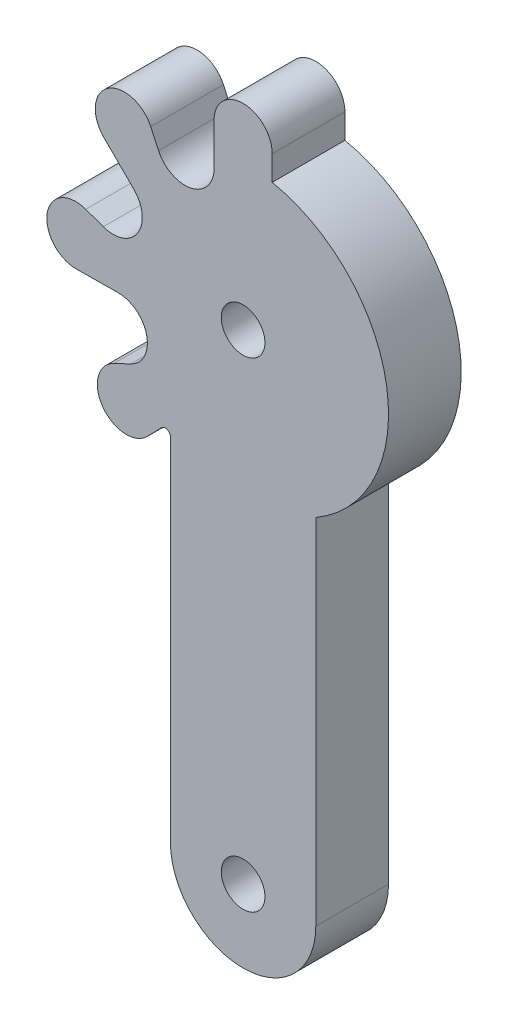
from build123d import *

# Parameters (mm, degrees)
SKETCH2_R           = 1.5
BOSS_EXTRUDE1_DEPTH = 5


with BuildPart() as part:
    # Sketch2 → Boss-Extrude1 (new body)
    with BuildSketch(Plane.XY):
        with BuildLine():
            Line((5, -33), (5, -8.660254038))
            ThreePointArc((5, -8.660254038), (9.870667346, 1.603098918), (2.002269745, 9.797495388))
            Line((2.002269745, 9.797495388), (2.00266405, 11.49953636))
            Line((2.00266405, 11.49953636), (2.002664157, 11.499999691))
            ThreePointArc((2.002664157, 11.499999691), (0.002664157, 13.499999691), (-1.997335843, 11.499999691))
            Line((-1.997335843, 11.499999691), (-1.998003665, 8.617307095))
            ThreePointArc((-1.998003665, 8.617307095), (-3.567262635, 6.664705601), (-5.812270881, 7.776085051))
            Line((-5.812270881, 7.776085051), (-6.351761581, 8.938967191))
            ThreePointArc((-6.351761581, 8.938967191), (-9.315039529, 9.734283484), (-9.574251776, 6.677102885))
            Line((-9.574251776, 6.677102885), (-7.526953052, 4.647039677))
            ThreePointArc((-7.526953052, 4.647039677), (-7.244787999, 2.157941439), (-9.614515081, 1.345771067))
            Line((-9.614515081, 1.345771067), (-10.820227093, 1.781203427))
            ThreePointArc((-10.820227093, 1.781203427), (-13.469614339, 0.244947506), (-11.499566198, -2.099886252))
            Line((-11.499566198, -2.099886252), (-11.463831285, -2.099566981))
            Line((-11.463831285, -2.099566981), (-8.600020221, -2.073980428))
            ThreePointArc((-8.600020221, -2.073980428), (-6.633040893, -3.625608638), (-7.724488765, -5.880669462))
            Line((-7.724488765, -5.880669462), (-7.993660259, -6.008443697))
            Line((-7.993660259, -6.008443697), (-8.882563754, -6.430401321))
            ThreePointArc((-8.882563754, -6.430401321), (-9.651698384, -9.400582629), (-6.592349134, -9.632805038))
            Line((-6.592349134, -9.632805038), (-5.601479532, -8.615725566))
            ThreePointArc((-5.601479532, -8.615725566), (-5.218458324, -8.535632344), (-5, -8.860280046))
            Line((-5, -8.860280046), (-5, -33))
            ThreePointArc((-5, -33), (0, -38), (5, -33))
        make_face()
        with Locations((0, -33)):
            Circle(SKETCH2_R, mode=Mode.SUBTRACT)
        Circle(SKETCH2_R, mode=Mode.SUBTRACT)
    extrude(amount=BOSS_EXTRUDE1_DEPTH)


solid = part.part
